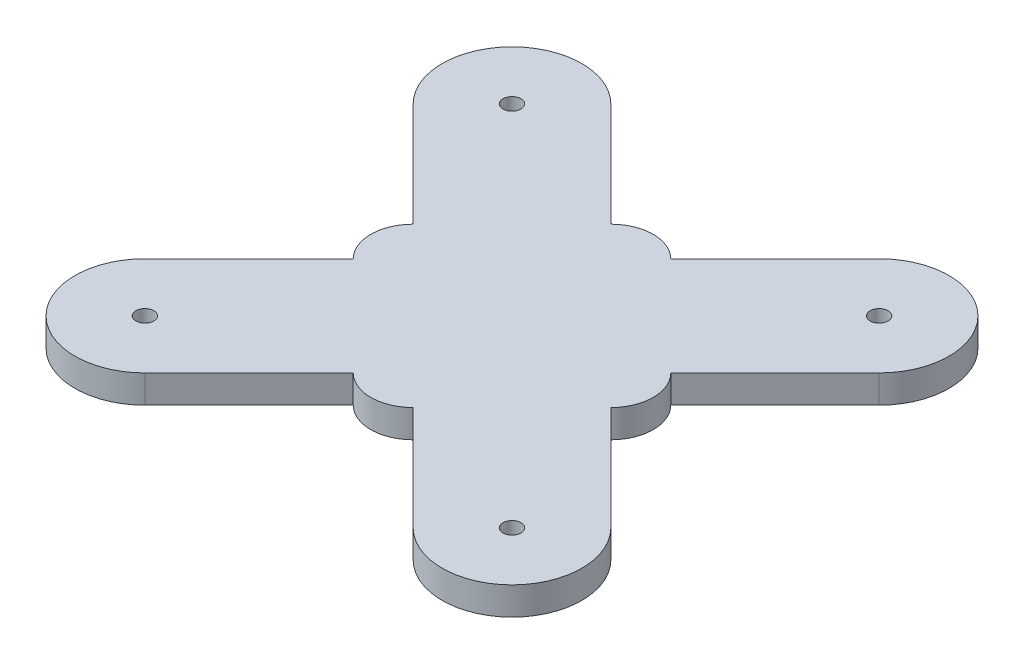
from build123d import *

# Parameters (mm, degrees)
SKETCH1_R           = 3.2
BOSS_EXTRUDE1_DEPTH = 10


with BuildPart() as part:
    # Sketch1 → Boss-Extrude1 (new body)
    with BuildSketch(Plane(origin=(0, 0, 0), x_dir=(1, 0, 0), z_dir=(0, 1, 0))):
        with BuildLine():
            Line((-47.977195104, 83.332534163), (-10.719183363, 46.074522422))
            ThreePointArc((-10.719183363, 46.074522422), (0, 50.514553548), (10.719183363, 46.074522422))
            Line((10.719183363, 46.074522422), (47.977195104, 83.332534163))
            ThreePointArc((47.977195104, 83.332534163), (83.332534163, 83.332534163), (83.332534163, 47.977195104))
            Line((83.332534163, 47.977195104), (46.074522422, 10.719183363))
            ThreePointArc((46.074522422, 10.719183363), (50.514553548, 0), (46.074522422, -10.719183363))
            Line((46.074522422, -10.719183363), (83.332534163, -47.977195104))
            ThreePointArc((83.332534163, -47.977195104), (83.332534163, -83.332534163), (47.977195104, -83.332534163))
            Line((47.977195104, -83.332534163), (10.719183363, -46.074522422))
            ThreePointArc((10.719183363, -46.074522422), (0, -50.514553548), (-10.719183363, -46.074522422))
            Line((-10.719183363, -46.074522422), (-47.977195104, -83.332534163))
            ThreePointArc((-47.977195104, -83.332534163), (-83.332534163, -83.332534163), (-83.332534163, -47.977195104))
            Line((-83.332534163, -47.977195104), (-46.074522422, -10.719183363))
            ThreePointArc((-46.074522422, -10.719183363), (-50.514553548, 0), (-46.074522422, 10.719183363))
            Line((-46.074522422, 10.719183363), (-83.332534163, 47.977195104))
            ThreePointArc((-83.332534163, 47.977195104), (-83.332534163, 83.332534163), (-47.977195104, 83.332534163))
        make_face()
        with Locations((-65.654864633, 65.654864633)):
            Circle(SKETCH1_R, mode=Mode.SUBTRACT)
        with Locations((65.654864633, -65.654864633)):
            Circle(SKETCH1_R, mode=Mode.SUBTRACT)
        with Locations((65.654864633, 65.654864633)):
            Circle(SKETCH1_R, mode=Mode.SUBTRACT)
        with Locations((-65.654864633, -65.654864633)):
            Circle(SKETCH1_R, mode=Mode.SUBTRACT)
    extrude(amount=BOSS_EXTRUDE1_DEPTH)


solid = part.part
